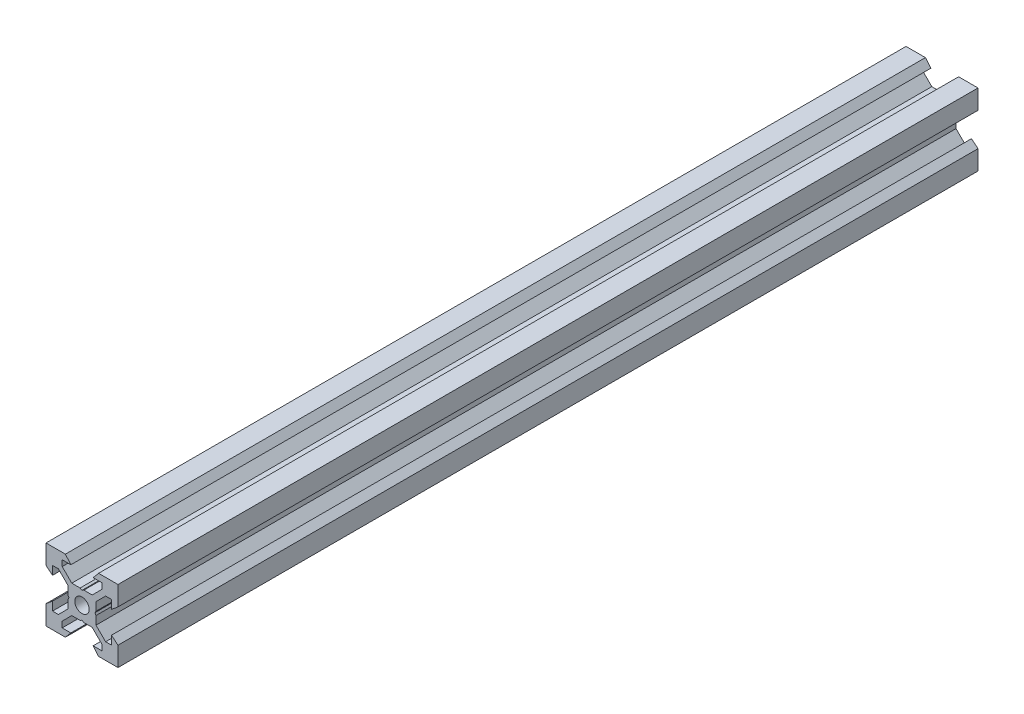
from build123d import *

# Parameters (mm, degrees)
SKETCH1_R           = 2
BOSS_EXTRUDE1_DEPTH = 119.5


with BuildPart() as part:
    # Sketch1 → Boss-Extrude1 (new body, symmetric)
    with BuildSketch(Plane.XY):
        Polygon((10, 10), (10, 4.610379336), (8.2, 3.1), (8.2, 5.5), (6.560660172, 5.5), (3.9, 2.839339828), (3.9, 0.519615242), (3.6, 0), (3.9, -0.519615242), (3.9, -2.839339828), (6.560660172, -5.5), (8.2, -5.5), (8.2, -3.1), (10, -4.610379336), (10, -10), (4.610379336, -10), (3.1, -8.2), (5.5, -8.2), (5.5, -6.560660172), (2.839339828, -3.9), (0.519615242, -3.9), (0, -3.6), (-0.519615242, -3.9), (-2.839339828, -3.9), (-5.5, -6.560660172), (-5.5, -8.2), (-3.1, -8.2), (-4.610379336, -10), (-10, -10), (-10, -4.610379336), (-8.2, -3.1), (-8.2, -5.5), (-6.560660172, -5.5), (-3.9, -2.839339828), (-3.9, -0.519615242), (-3.6, 0), (-3.9, 0.519615242), (-3.9, 2.839339828), (-6.560660172, 5.5), (-8.2, 5.5), (-8.2, 3.1), (-10, 4.610379336), (-10, 10), (-4.610379336, 10), (-3.1, 8.2), (-5.5, 8.2), (-5.5, 6.560660172), (-2.839339828, 3.9), (-0.519615242, 3.9), (0, 3.6), (0.519615242, 3.9), (2.839339828, 3.9), (5.5, 6.560660172), (5.5, 8.2), (3.1, 8.2), (4.610379336, 10), align=None)
        Circle(SKETCH1_R, mode=Mode.SUBTRACT)
    extrude(amount=BOSS_EXTRUDE1_DEPTH, both=True)


solid = part.part
